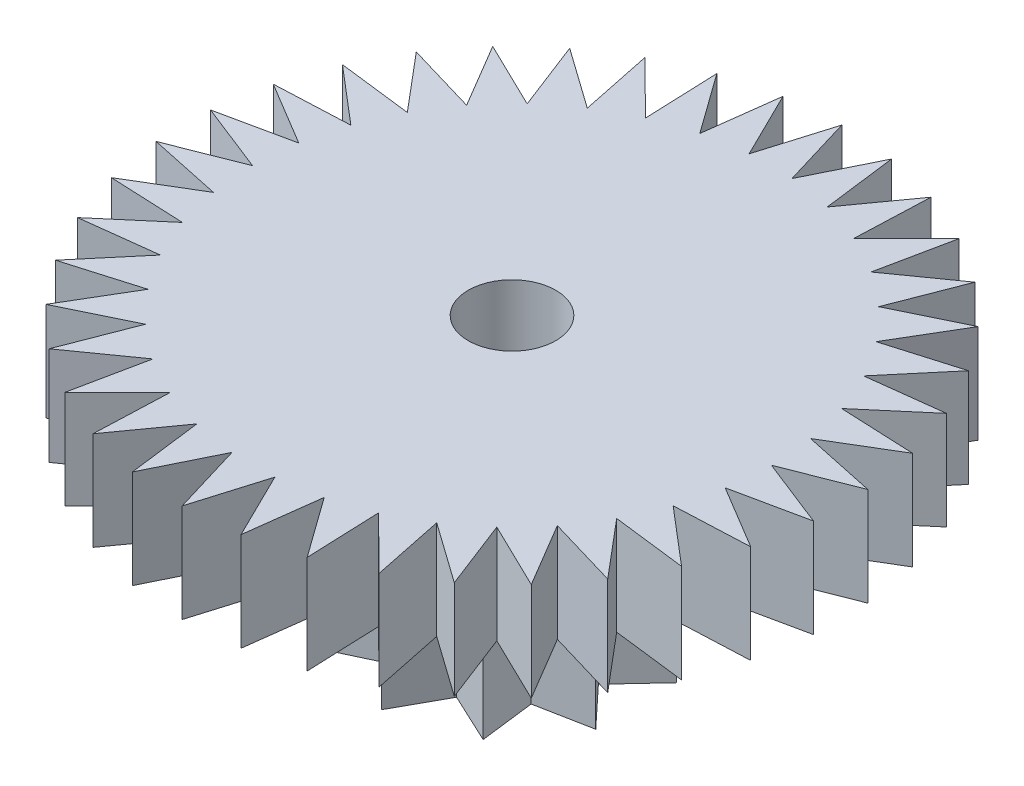
from build123d import *

# Parameters (mm, degrees)
SKETCH2_R          = 0.8
CUT_EXTRUDE1_DEPTH = 6.05
CUT_EXTRUDE2_DEPTH = 6.05
CIRPATTERN1_COUNT  = 38
CUT_EXTRUDE3_DEPTH = 3.25
CIRPATTERN2_COUNT  = 10


with BuildPart() as part:
    # Sketch1 → Revolve1 (revolve)
    with BuildSketch(Plane.XY):
        Polygon((-6.03, 5.05), (-6.03, 3.25), (-2.385, 3.25), (-2.385, 0), (0, 0), (0, 5.05), align=None)
    revolve(axis=Axis((0, 5.05, 0), (0, -1, 0)))

    # Sketch2 → Cut-Extrude1 (cut, through all)
    with BuildSketch(Plane(origin=(0, 5.05, 0), x_dir=(1, 0, 0), z_dir=(0, 1, 0))):
        Circle(SKETCH2_R)
    extrude(amount=-CUT_EXTRUDE1_DEPTH, mode=Mode.SUBTRACT)

    # Sketch3 → Cut-Extrude2 (cut, through all)
    with BuildSketch(Plane(origin=(0, 5.05, 0), x_dir=(1, 0, 0), z_dir=(0, 1, 0))):
        with BuildLine():
            Line((0, 6.03), (0.391691416, 4.727012418))
            Line((0.391691416, 4.727012418), (0.992505379, 5.94775866))
            ThreePointArc((0.992505379, 5.94775866), (0.497953453, 6.009404493), (0, 6.03))
        make_face()
    cut_extrude2 = extrude(amount=-CUT_EXTRUDE2_DEPTH, mode=Mode.SUBTRACT)

    # CirPattern1: Cut-Extrude2 ×38 about axis
    cirpattern1_axis = Axis((0, 0, 0), (0, 1, 0))
    for i in range(1, CIRPATTERN1_COUNT):
        add(cut_extrude2.rotate(cirpattern1_axis, i * 360 / CIRPATTERN1_COUNT), mode=Mode.SUBTRACT)

    # Sketch4 → Cut-Extrude3 (cut)
    with BuildSketch(Plane.XZ):
        with BuildLine():
            Line((1.401867827, 1.929505532), (0.488038951, 1.502029444))
            Line((0.488038951, 1.502029444), (0, 2.385))
            ThreePointArc((0, 2.385), (0.737005532, 2.268269791), (1.401867827, 1.929505532))
        make_face()
    cut_extrude3 = extrude(amount=-CUT_EXTRUDE3_DEPTH, mode=Mode.SUBTRACT)

    # CirPattern2: Cut-Extrude3 ×10 about axis
    cirpattern2_axis = Axis((0, 0, 0), (0, 1, 0))
    for i in range(1, CIRPATTERN2_COUNT):
        add(cut_extrude3.rotate(cirpattern2_axis, i * 360 / CIRPATTERN2_COUNT), mode=Mode.SUBTRACT)


solid = part.part
